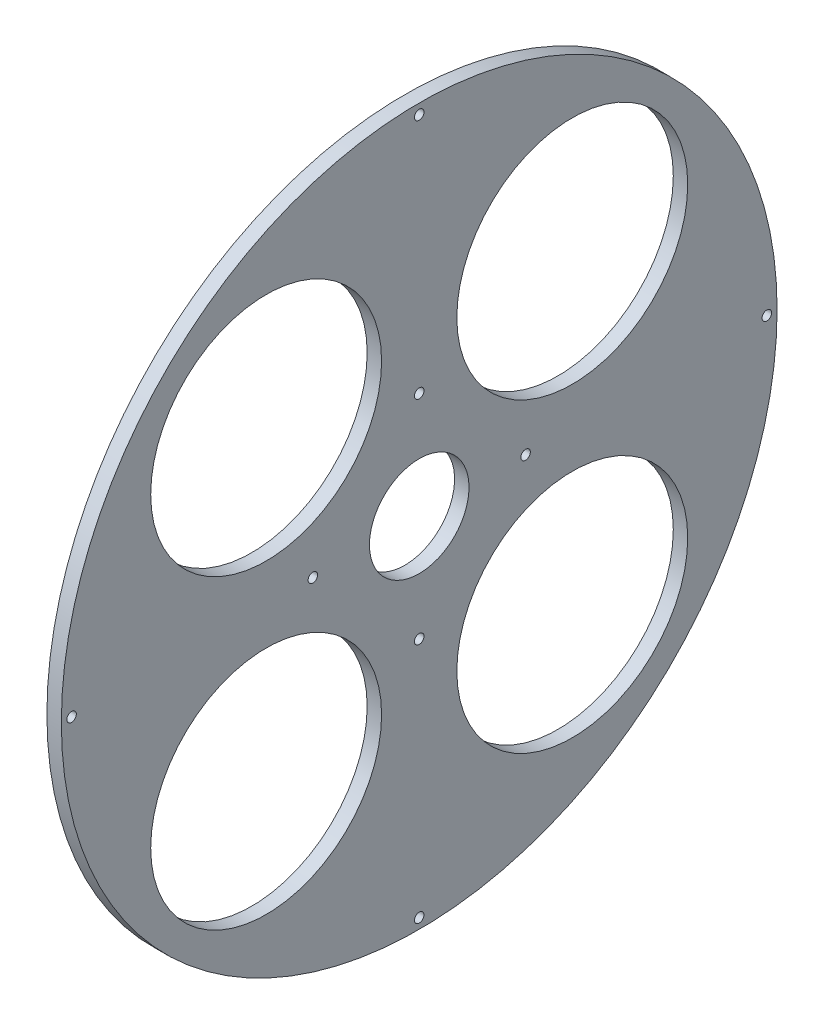
from build123d import *

# Parameters (mm, degrees)
ESBO_O1_W               = 10
ESBO_O1_H               = 213.5
FURO_COM_FOLGA_DE_M61_D = 6.6
ESBO_O7_R               = 80
CORTE_EXTRUS_O1_DEPTH   = 11
FURO_COM_FOLGA_DE_M62_D = 6.6


with BuildPart() as part:
    # Esboço1 → Revolução1 (revolve)
    with BuildSketch(Plane.XY):
        with Locations((0, 141.25)):
            Rectangle(ESBO_O1_W, ESBO_O1_H)
    revolve(axis=Axis((0, 0, 0), (1, 0, 0)))

    # Furo com folga de M61 (through all)
    with Locations(Plane.ZY.offset(18.8)):
        with Locations((0, 73.7), (73.7, 0), (0, -73.7), (-73.7, 0), (0, 0)):
            Hole(FURO_COM_FOLGA_DE_M61_D / 2)

    # Esboço7 → Corte-extrusão1 (cut, through all)
    with BuildSketch(Plane.ZY.offset(5)):
        with Locations((106.066017178, 106.066017178)):
            Circle(ESBO_O7_R)
        with Locations((106.066017178, -106.066017178)):
            Circle(ESBO_O7_R)
        with Locations((-106.066017178, -106.066017178)):
            Circle(ESBO_O7_R)
        with Locations((-106.066017178, 106.066017178)):
            Circle(ESBO_O7_R)
    extrude(amount=-CORTE_EXTRUS_O1_DEPTH, mode=Mode.SUBTRACT)

    # Furo com folga de M62 (through all)
    with Locations(Plane(origin=(14.343621622, 0, 0), x_dir=(0, 0, -1), z_dir=(1, 0, 0))):
        with Locations((0, 240.895271507), (240.895271507, 0), (0, -240.895271507), (-240.895271507, 0), (0, 0)):
            Hole(FURO_COM_FOLGA_DE_M62_D / 2)


solid = part.part
